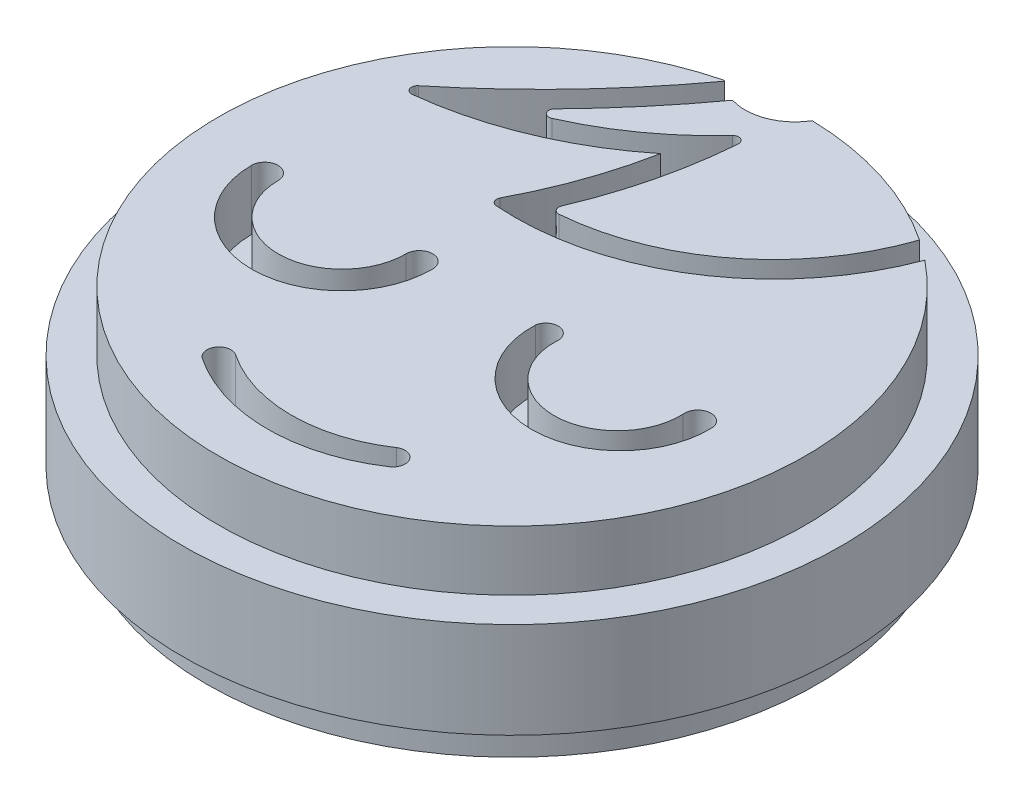
from build123d import *

# Parameters (mm, degrees)
SALIENTE_EXTRUIR1_DEPTH   = 5
SALIENTE_EXTRUIR1_2_DEPTH = 5
CROQUIS2_R                = 27.5
SALIENTE_EXTRUIR2_DEPTH   = 8
CROQUIS3_R                = 25.5
CROQUIS3_R_2              = 24
SALIENTE_EXTRUIR3_DEPTH   = 3
CROQUIS4_R                = 24
CORTAR_EXTRUIR1_DEPTH     = 3


with BuildPart() as part:
    # Croquis1 → Saliente-Extruir1 (new body)
    with BuildSketch(Plane(origin=(0, 0, 0), x_dir=(1, 0, 0), z_dir=(0, 1, 0))):
        with BuildLine():
            ThreePointArc((-6.024394544, 23.747771903), (-5.19984533, -23.941838036), (15.332388636, 19.109365733))
            ThreePointArc((15.332388636, 19.109365733), (6.749911309, 8.499710515), (-6.481910722, 5.161659186))
            ThreePointArc((-6.481910722, 5.161659186), (-6.882152879, 5.418254788), (-6.886809038, 5.893663462))
            ThreePointArc((-6.886809038, 5.893663462), (-4.77910195, 10.712326415), (-3.398196642, 15.787269012))
            ThreePointArc((-3.398196642, 15.787269012), (-10.284746472, 11.706352258), (-18.035485402, 9.705228534))
            ThreePointArc((-18.035485402, 9.705228534), (-18.552255418, 10.008822773), (-18.406444405, 10.590165925))
            ThreePointArc((-18.406444405, 10.590165925), (-11.764118021, 16.738249367), (-5.966725479, 23.688765141))
            ThreePointArc((-5.966725479, 23.688765141), (-5.995706248, 23.718125601), (-6.024394544, 23.747771903))
        make_face()
        with BuildLine():
            ThreePointArc((-4.563193765, -2.059824722), (-12.054197272, -9.623389101), (-19.617761652, -2.132385594))
            ThreePointArc((-19.617761652, -2.132385594), (-18.516794481, -1.020754013), (-17.4051629, -2.121721183))
            ThreePointArc((-17.4051629, -2.121721183), (-12.064848376, -7.410803529), (-6.775766031, -2.070489005))
            ThreePointArc((-6.775766031, -2.070489005), (-5.67481204, -0.958870731), (-4.563193765, -2.059824722))
        make_face(mode=Mode.SUBTRACT)
        with BuildLine():
            ThreePointArc((7.93388408, -18.140011178), (0.114097404, -20.519185991), (-7.705689271, -18.140011178))
            ThreePointArc((-7.705689271, -18.140011178), (-7.979292605, -16.752516596), (-6.591798022, -16.478913263))
            ThreePointArc((-6.591798022, -16.478913263), (0.114097404, -18.519185991), (6.819992831, -16.478913263))
            ThreePointArc((6.819992831, -16.478913263), (8.207487413, -16.752516596), (7.93388408, -18.140011178))
        make_face(mode=Mode.SUBTRACT)
        with BuildLine():
            ThreePointArc((18.566554033, -1.822088449), (11.169349937, -9.530541219), (3.772145841, -1.822088449))
            ThreePointArc((3.772145841, -1.822088449), (4.944999806, -0.954199424), (5.812888831, -2.127053389))
            ThreePointArc((5.812888831, -2.127053389), (11.092516644, -7.59016676), (16.372144456, -2.127053389))
            ThreePointArc((16.372144456, -2.127053389), (17.316866775, -0.877366131), (18.566554033, -1.822088449))
        make_face(mode=Mode.SUBTRACT)
    extrude(amount=SALIENTE_EXTRUIR1_DEPTH)



with BuildPart() as body_2:
    # Croquis1 → Saliente-Extruir1 2 (new body)
    with BuildSketch(Plane(origin=(0, 0, 0), x_dir=(1, 0, 0), z_dir=(0, 1, 0))):
        with BuildLine():
            ThreePointArc((-3.237616322, 7.170010781), (7.168200526, 11.242778225), (13.650668654, 20.344759652))
            ThreePointArc((13.650668654, 20.344759652), (7.399029371, 23.35603486), (0.553855765, 24.493738869))
            ThreePointArc((0.553855765, 24.493738869), (-1.528467266, 22.741552063), (-4.248394951, 22.650881235))
            ThreePointArc((-4.248394951, 22.650881235), (-7.499015993, 18.503713558), (-11.043045611, 14.604304504))
            ThreePointArc((-11.043045611, 14.604304504), (-11.096230859, 13.969574186), (-10.482918218, 13.797647311))
            ThreePointArc((-10.482918218, 13.797647311), (-5.775579982, 16.492523924), (-1.716909146, 20.090938058))
            ThreePointArc((-1.716909146, 20.090938058), (-1.149234355, 20.211325601), (-0.850096282, 19.714068884))
            ThreePointArc((-0.850096282, 19.714068884), (-1.814955726, 13.671675172), (-3.739754637, 7.863351432))
            ThreePointArc((-3.739754637, 7.863351432), (-3.684337904, 7.37498369), (-3.237616322, 7.170010781))
        make_face()
    extrude(amount=SALIENTE_EXTRUIR1_2_DEPTH)


with BuildPart() as part_1:
    add(part.part)

    add(body_2.part)  # Saliente-Extruir2 merges body 2
    # Croquis2 → Saliente-Extruir2 (add)
    with BuildSketch(Plane(origin=(0, 0, 0), x_dir=(-1, 0, 0), z_dir=(0, -1, 0))):
        Circle(CROQUIS2_R)
    extrude(amount=SALIENTE_EXTRUIR2_DEPTH)

    # Croquis3 → Saliente-Extruir3 (add)
    with BuildSketch(Plane(origin=(0, -8, 0), x_dir=(-1, 0, 0), z_dir=(0, -1, 0))):
        Circle(CROQUIS3_R)
        Circle(CROQUIS3_R_2, mode=Mode.SUBTRACT)
    extrude(amount=SALIENTE_EXTRUIR3_DEPTH)

    # Croquis4 → Cortar-Extruir1 (cut)
    with BuildSketch(Plane(origin=(0, -8, 0), x_dir=(-1, 0, 0), z_dir=(0, -1, 0))):
        Circle(CROQUIS4_R)
    extrude(amount=-CORTAR_EXTRUIR1_DEPTH, mode=Mode.SUBTRACT)


solid = part_1.part
